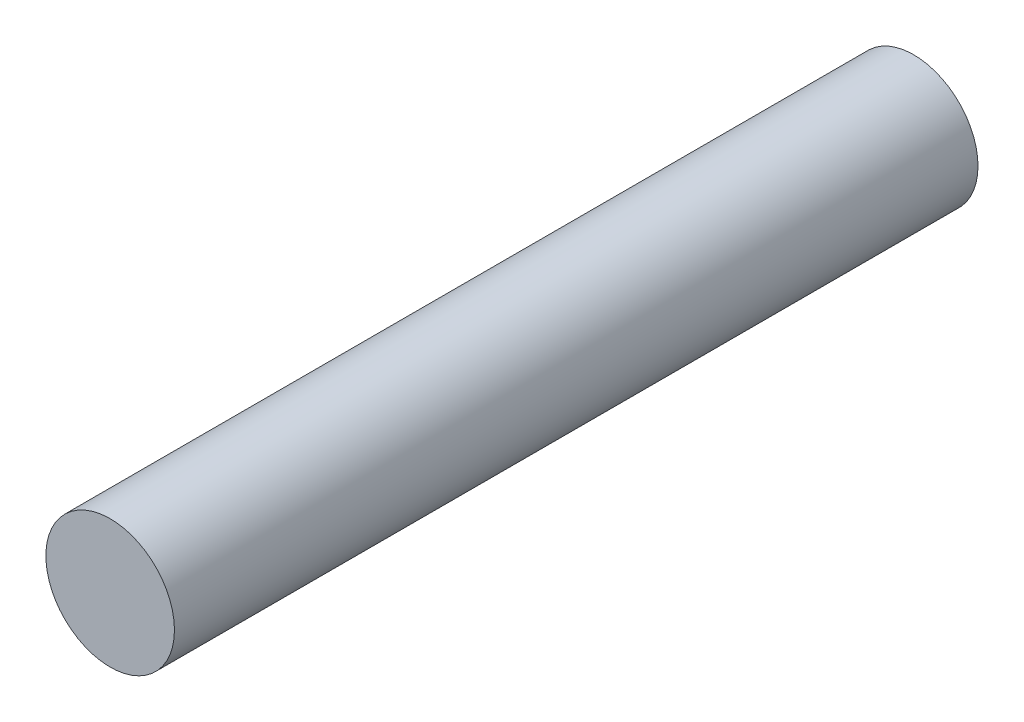
from build123d import *

# Parameters (mm, degrees)
SKETCH_1_R      = 8
EXTRUDE_1_DEPTH = 100


with BuildPart() as part:
    # 草图1 → 凸台-拉伸1 (new body)
    with BuildSketch(Plane.XY):
        with Locations((-11.087072749, -4.858380193)):
            Circle(SKETCH_1_R)
    extrude(amount=EXTRUDE_1_DEPTH)


solid = part.part
